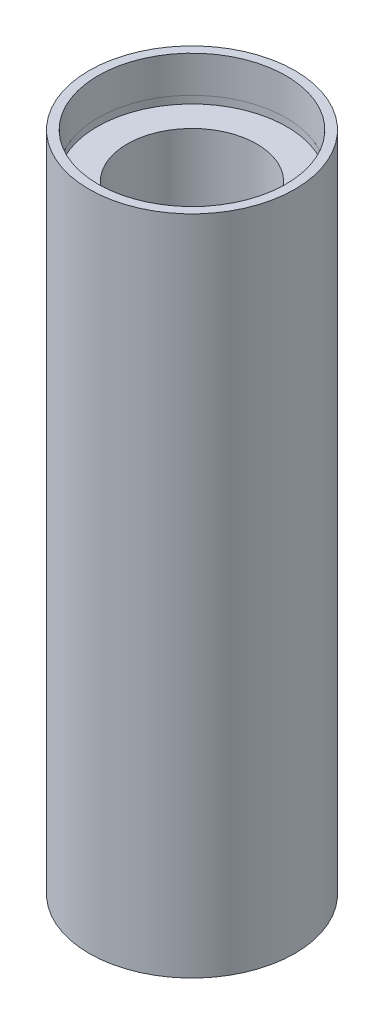
from build123d import *


with BuildPart() as part:
    # 草图1 → 旋转1 (revolve)
    with BuildSketch(Plane.XY, mode=Mode.PRIVATE) as revolve_1_sk:
        Polygon((11.1, 0), (11.1, 4.5), (11.7, 4.5), (11.7, 5.5), (8, 5.5), (8, 76.2), (11.7, 76.2), (11.7, 77.2), (11.6, 77.2), (11.6, 81.7), (12.7, 81.7), (12.7, 0), align=None)
    revolve(revolve_1_sk.sketch.rotate(Axis((0, 161.376166943, 0), (0, -1, 0)), 90), axis=Axis((0, 161.376166943, 0), (0, -1, 0)))  # turned: the seam where the file's is


solid = part.part
